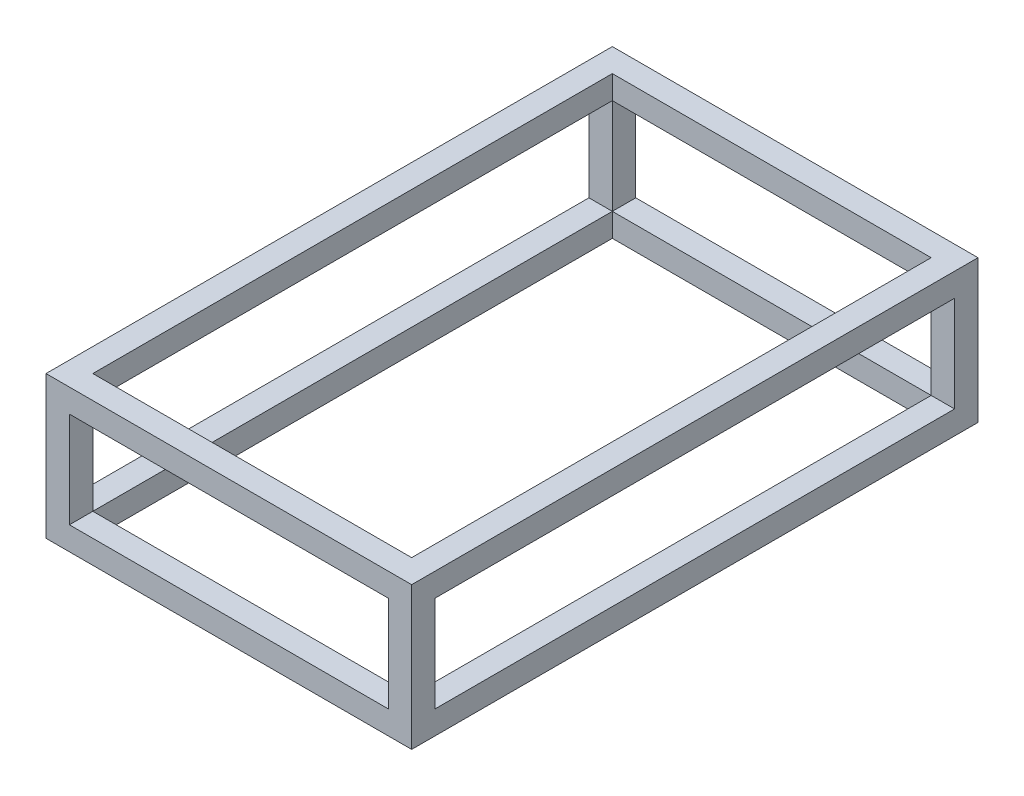
from build123d import *

# Parameters (mm, degrees)
SKETCH2_W            = 50
SKETCH2_H            = 50
BOSS_EXTRUDE1_DEPTH  = 1209.675
SKETCH3_W            = 50
SKETCH3_H            = 50
BOSS_EXTRUDE2_DEPTH  = 731.05
SKETCH4_W            = 50
SKETCH4_H            = 50
BOSS_EXTRUDE3_DEPTH  = 1159.68
SKETCH6_W            = 50
SKETCH6_H            = 50
BOSS_EXTRUDE4_DEPTH  = 681.05
SKETCH8_W            = 50
SKETCH8_H            = 50
BOSS_EXTRUDE5_DEPTH  = 254.8
SKETCH9_W            = 50
SKETCH9_H            = 50
BOSS_EXTRUDE6_DEPTH  = 731.05
SKETCH10_W           = 50
SKETCH10_H           = 50
BOSS_EXTRUDE7_DEPTH  = 204.8
SKETCH11_W           = 50
SKETCH11_H           = 49.995
BOSS_EXTRUDE8_DEPTH  = 254.8
SKETCH12_W           = 50
SKETCH12_H           = 50
BOSS_EXTRUDE9_DEPTH  = 1109.8
SKETCH13_W           = 50
SKETCH13_H           = 50
BOSS_EXTRUDE10_DEPTH = 1109.8
SKETCH14_W           = 50
SKETCH14_H           = 49.995
BOSS_EXTRUDE11_DEPTH = 254.8
SKETCH15_W           = 49.995
SKETCH15_H           = 50
BOSS_EXTRUDE12_DEPTH = 681.05


with BuildPart() as part:
    # Sketch2 → Boss-Extrude1 (new body)
    with BuildSketch(Plane.XY):
        Rectangle(SKETCH2_W, SKETCH2_H)
    extrude(amount=BOSS_EXTRUDE1_DEPTH)

    # Sketch3 → Boss-Extrude2 (add)
    with BuildSketch(Plane(origin=(25, 0, 0), x_dir=(0, 0, -1), z_dir=(1, 0, 0))):
        with Locations((-1184.675, 0)):
            Rectangle(SKETCH3_W, SKETCH3_H)
    extrude(amount=BOSS_EXTRUDE2_DEPTH)

    # Sketch4 → Boss-Extrude3 (add)
    with BuildSketch(Plane(origin=(0, 0, 1159.675), x_dir=(-1, 0, 0), z_dir=(0, 0, -1))):
        with Locations((-731.05, 0)):
            Rectangle(SKETCH4_W, SKETCH4_H)
    extrude(amount=BOSS_EXTRUDE3_DEPTH)

    # Sketch6 → Boss-Extrude4 (add)
    with BuildSketch(Plane.ZY.offset(-706.05)):
        with Locations((24.995, 0)):
            Rectangle(SKETCH6_W, SKETCH6_H)
    extrude(amount=BOSS_EXTRUDE4_DEPTH)

    # Sketch8 → Boss-Extrude5 (add)
    with BuildSketch(Plane(origin=(0, 25, 0), x_dir=(1, 0, 0), z_dir=(0, 1, 0))):
        with Locations((0, -1184.675)):
            Rectangle(SKETCH8_W, SKETCH8_H)
    extrude(amount=BOSS_EXTRUDE5_DEPTH)

    # Sketch9 → Boss-Extrude6 (add)
    with BuildSketch(Plane(origin=(25, 0, 0), x_dir=(0, 0, -1), z_dir=(1, 0, 0))):
        with Locations((-1184.675, 254.8)):
            Rectangle(SKETCH9_W, SKETCH9_H)
    extrude(amount=BOSS_EXTRUDE6_DEPTH)

    # Sketch10 → Boss-Extrude7 (add)
    with BuildSketch(Plane.XZ.offset(-229.8)):
        with Locations((731.05, 1184.675)):
            Rectangle(SKETCH10_W, SKETCH10_H)
    extrude(amount=BOSS_EXTRUDE7_DEPTH)

    # Sketch11 → Boss-Extrude8 (add)
    with BuildSketch(Plane(origin=(0, 25, 0), x_dir=(1, 0, 0), z_dir=(0, 1, 0))):
        with Locations((731.05, -24.9975)):
            Rectangle(SKETCH11_W, SKETCH11_H)
    extrude(amount=BOSS_EXTRUDE8_DEPTH)

    # Sketch12 → Boss-Extrude9 (add)
    with BuildSketch(Plane(origin=(0, 0, 1159.675), x_dir=(-1, 0, 0), z_dir=(0, 0, -1))):
        with Locations((-731.05, 254.8)):
            Rectangle(SKETCH12_W, SKETCH12_H)
    extrude(amount=BOSS_EXTRUDE9_DEPTH)

    # Sketch13 → Boss-Extrude10 (add)
    with BuildSketch(Plane(origin=(0, 0, 1159.675), x_dir=(-1, 0, 0), z_dir=(0, 0, -1))):
        with Locations((0, 254.8)):
            Rectangle(SKETCH13_W, SKETCH13_H)
    extrude(amount=BOSS_EXTRUDE10_DEPTH)

    # Sketch14 → Boss-Extrude11 (add)
    with BuildSketch(Plane(origin=(0, 25, 0), x_dir=(1, 0, 0), z_dir=(0, 1, 0))):
        with Locations((0, -24.9975)):
            Rectangle(SKETCH14_W, SKETCH14_H)
    extrude(amount=BOSS_EXTRUDE11_DEPTH)

    # Sketch15 → Boss-Extrude12 (add)
    with BuildSketch(Plane(origin=(25, 0, 0), x_dir=(0, 0, -1), z_dir=(1, 0, 0))):
        with Locations((-24.9975, 254.8)):
            Rectangle(SKETCH15_W, SKETCH15_H)
    extrude(amount=BOSS_EXTRUDE12_DEPTH)


solid = part.part
